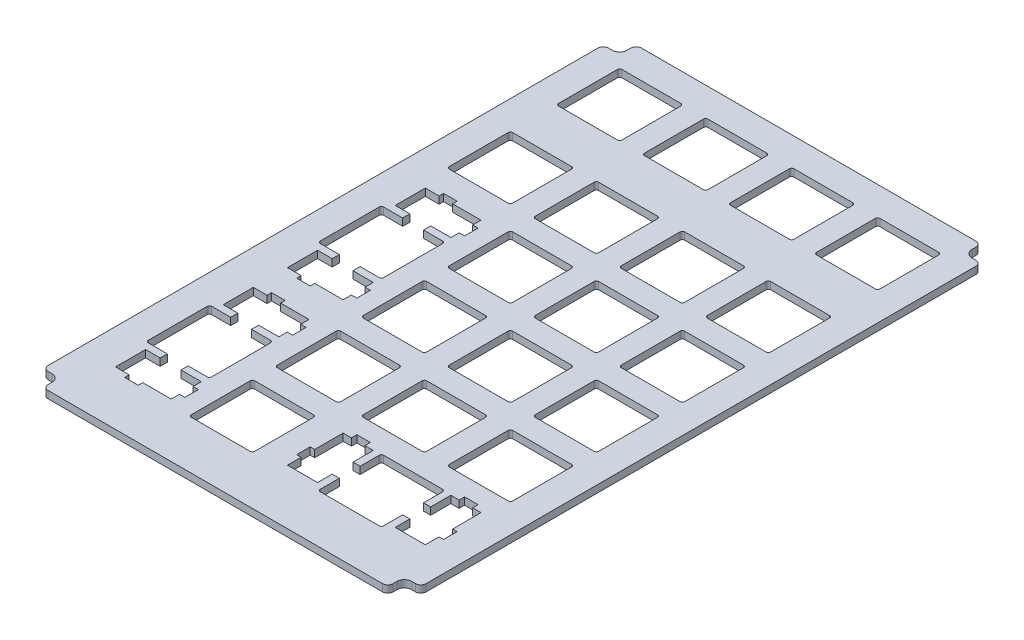
from build123d import *

# Parameters (mm, degrees)
EXTRUDE_1_DEPTH             = 1.6
CUT_EXTRUDE_3_DEPTH         = 1.6
PATTERN_LINEAR_1_COUNT      = 5
PATTERN_LINEAR_1_PITCH      = 19
PATTERN_LINEAR_1_COUNT_DIR2 = 4
PATTERN_LINEAR_1_PITCH_DIR2 = 19
PATTERN_LINEAR_2_COUNT      = 2
PATTERN_LINEAR_2_PITCH      = 100.15
PATTERN_LINEAR_2_COUNT_DIR2 = 4
PATTERN_LINEAR_2_PITCH_DIR2 = 19
CUT_EXTRUDE_2_DEPTH         = 1.6
SKETCH_7_W                  = 35.521117503
SKETCH_7_H                  = 15.86551154
EXTRUDE_2_DEPTH             = 1.6
CUT_EXTRUDE_4_DEPTH         = 1.6


with BuildPart() as part:
    # 草图1 → 凸台-拉伸1 (new body)
    with BuildSketch(Plane(origin=(0, 0, 0), x_dir=(1, 0, 0), z_dir=(0, 1, 0))):
        with BuildLine():
            Line((-11.350806884, 119.165811453), (-10.500806884, 119.165811453))
            ThreePointArc((-10.500806884, 119.165811453), (-9.334080695, 119.649085264), (-8.850806884, 120.815811453))
            Line((-8.850806884, 120.815811453), (-8.850806884, 121.665811453))
            ThreePointArc((-8.850806884, 121.665811453), (-8.513979683, 122.478984252), (-7.700806884, 122.815811453))
            Line((-7.700806884, 122.815811453), (66.199193116, 122.815811453))
            ThreePointArc((66.199193116, 122.815811453), (67.012365914, 122.478984252), (67.349193116, 121.665811453))
            Line((67.349193116, 121.665811453), (67.349193116, 120.815811453))
            ThreePointArc((67.349193116, 120.815811453), (67.832466927, 119.649085264), (68.999193116, 119.165811453))
            Line((68.999193116, 119.165811453), (69.849193116, 119.165811453))
            ThreePointArc((69.849193116, 119.165811453), (70.662365914, 118.828984252), (70.999193116, 118.015811453))
            Line((70.999193116, 118.015811453), (70.999193116, -3.47167721))
            ThreePointArc((70.999193116, -3.47167721), (70.662365914, -4.284850009), (69.849193116, -4.62167721))
            Line((69.849193116, -4.62167721), (68.999193116, -4.62167721))
            ThreePointArc((68.999193116, -4.62167721), (67.832466927, -5.104951021), (67.349193116, -6.27167721))
            Line((67.349193116, -6.27167721), (67.349193116, -7.12167721))
            ThreePointArc((67.349193116, -7.12167721), (67.012365914, -7.934850009), (66.199193116, -8.27167721))
            Line((66.199193116, -8.27167721), (-7.700806884, -8.27167721))
            ThreePointArc((-7.700806884, -8.27167721), (-8.513979683, -7.934850009), (-8.850806884, -7.12167721))
            Line((-8.850806884, -7.12167721), (-8.850806884, -6.27167721))
            ThreePointArc((-8.850806884, -6.27167721), (-9.334080695, -5.104951021), (-10.500806884, -4.62167721))
            Line((-10.500806884, -4.62167721), (-11.350806884, -4.62167721))
            ThreePointArc((-11.350806884, -4.62167721), (-12.163979683, -4.284850009), (-12.500806884, -3.47167721))
            Line((-12.500806884, -3.47167721), (-12.500806884, 118.015811453))
            ThreePointArc((-12.500806884, 118.015811453), (-12.163979683, 118.828984252), (-11.350806884, 119.165811453))
        make_face()
    extrude(amount=EXTRUDE_1_DEPTH)

    # 草图6 → 切除-拉伸3 (cut)
    with BuildSketch(Plane.XZ):
        with BuildLine():
            Line((51.249193116, -2.415811453), (64.249193116, -2.415811453))
            ThreePointArc((64.249193116, -2.415811453), (64.602746506, -2.562258063), (64.749193116, -2.915811453))
            Line((64.749193116, -2.915811453), (64.749193116, -15.915811453))
            ThreePointArc((64.749193116, -15.915811453), (64.602746506, -16.269364844), (64.249193116, -16.415811453))
            Line((64.249193116, -16.415811453), (51.249193116, -16.415811453))
            ThreePointArc((51.249193116, -16.415811453), (50.895639725, -16.269364844), (50.749193116, -15.915811453))
            Line((50.749193116, -15.915811453), (50.749193116, -2.915811453))
            ThreePointArc((50.749193116, -2.915811453), (50.895639725, -2.562258063), (51.249193116, -2.415811453))
        make_face()
    cut_extrude_3 = extrude(amount=-CUT_EXTRUDE_3_DEPTH, mode=Mode.SUBTRACT)

    # 阵列(线性)1: Cut-Extrude 3 5 × 4, 4 skipped
    with Locations(*[(-j * PATTERN_LINEAR_1_PITCH_DIR2, 0, -i * PATTERN_LINEAR_1_PITCH) for i in range(PATTERN_LINEAR_1_COUNT) for j in range(PATTERN_LINEAR_1_COUNT_DIR2) if (i, j) not in ((0, 0), (0, 3), (1, 3), (2, 3), (3, 3))]):
        add(cut_extrude_3, mode=Mode.SUBTRACT)

    # 阵列(线性)2: Cut-Extrude 3 2 × 4, 3 skipped
    with Locations(*[(-j * PATTERN_LINEAR_2_PITCH_DIR2, 0, -i * PATTERN_LINEAR_2_PITCH) for i in range(PATTERN_LINEAR_2_COUNT) for j in range(PATTERN_LINEAR_2_COUNT_DIR2) if (i, j) not in ((0, 0), (0, 1), (0, 2), (0, 3))]):
        add(cut_extrude_3, mode=Mode.SUBTRACT)

    # 草图3 → 切除-拉伸2 (cut)
    with BuildSketch(Plane(origin=(0, 1.6, 0), x_dir=(1, 0, 0), z_dir=(0, 1, 0))):
        with BuildLine():
            Line((-6.250806884, 12.415811453), (-6.250806884, 25.415811453))
            ThreePointArc((-6.250806884, 25.415811453), (-6.104360275, 25.769364844), (-5.750806884, 25.915811453))
            Line((-5.750806884, 25.915811453), (-1.550806884, 25.915811453))
            Line((-1.550806884, 25.915811453), (-1.550806884, 27.495811453))
            Line((-1.550806884, 27.495811453), (-4.780806884, 27.495811453))
            Line((-4.780806884, 27.495811453), (-4.780806884, 34.145811453))
            Line((-4.780806884, 34.145811453), (-1.750806884, 34.145811453))
            Line((-1.750806884, 34.145811453), (-1.750806884, 35.145811453))
            Line((-1.750806884, 35.145811453), (1.249193116, 35.145811453))
            Line((1.249193116, 35.145811453), (1.249193116, 34.145811453))
            Line((1.249193116, 34.145811453), (7.519193116, 34.145811453))
            Line((7.519193116, 34.145811453), (7.519193116, 32.320811453))
            Line((7.519193116, 32.320811453), (8.719193116, 32.320811453))
            Line((8.719193116, 32.320811453), (8.719193116, 29.320811453))
            Line((8.719193116, 29.320811453), (7.519193116, 29.320811453))
            Line((7.519193116, 29.320811453), (7.519193116, 27.495811453))
            Line((7.519193116, 27.495811453), (3.049193116, 27.495811453))
            Line((3.049193116, 27.495811453), (3.049193116, 25.915811453))
            Line((3.049193116, 25.915811453), (7.249193116, 25.915811453))
            ThreePointArc((7.249193116, 25.915811453), (7.602746506, 25.769364844), (7.749193116, 25.415811453))
            Line((7.749193116, 25.415811453), (7.749193116, 12.415811453))
            ThreePointArc((7.749193116, 12.415811453), (7.602746506, 12.062258063), (7.249193116, 11.915811453))
            Line((7.249193116, 11.915811453), (3.049193116, 11.915811453))
            Line((3.049193116, 11.915811453), (3.049193116, 10.335811453))
            Line((3.049193116, 10.335811453), (7.519193116, 10.335811453))
            Line((7.519193116, 10.335811453), (7.519193116, 8.510811453))
            Line((7.519193116, 8.510811453), (8.719193116, 8.510811453))
            Line((8.719193116, 8.510811453), (8.719193116, 5.510811453))
            Line((8.719193116, 5.510811453), (7.519193116, 5.510811453))
            Line((7.519193116, 5.510811453), (7.519193116, 3.685811453))
            Line((7.519193116, 3.685811453), (1.249193116, 3.685811453))
            Line((1.249193116, 3.685811453), (1.249193116, 2.685811453))
            Line((1.249193116, 2.685811453), (-1.750806884, 2.685811453))
            Line((-1.750806884, 2.685811453), (-1.750806884, 3.685811453))
            Line((-1.750806884, 3.685811453), (-4.780806884, 3.685811453))
            Line((-4.780806884, 3.685811453), (-4.780806884, 10.335811453))
            Line((-4.780806884, 10.335811453), (-1.550806884, 10.335811453))
            Line((-1.550806884, 10.335811453), (-1.550806884, 11.915811453))
            Line((-1.550806884, 11.915811453), (-5.750806884, 11.915811453))
            ThreePointArc((-5.750806884, 11.915811453), (-6.104360275, 12.062258063), (-6.250806884, 12.415811453))
        make_face()
        with BuildLine():
            Line((-6.250806884, 50.415811453), (-6.250806884, 63.415811453))
            ThreePointArc((-6.250806884, 63.415811453), (-6.104360275, 63.769364844), (-5.750806884, 63.915811453))
            Line((-5.750806884, 63.915811453), (-1.550806884, 63.915811453))
            Line((-1.550806884, 63.915811453), (-1.550806884, 65.495811453))
            Line((-1.550806884, 65.495811453), (-4.780806884, 65.495811453))
            Line((-4.780806884, 65.495811453), (-4.780806884, 72.145811453))
            Line((-4.780806884, 72.145811453), (-1.750806884, 72.145811453))
            Line((-1.750806884, 72.145811453), (-1.750806884, 73.145811453))
            Line((-1.750806884, 73.145811453), (1.249193116, 73.145811453))
            Line((1.249193116, 73.145811453), (1.249193116, 72.145811453))
            Line((1.249193116, 72.145811453), (7.519193116, 72.145811453))
            Line((7.519193116, 72.145811453), (7.519193116, 70.320811453))
            Line((7.519193116, 70.320811453), (8.719193116, 70.320811453))
            Line((8.719193116, 70.320811453), (8.719193116, 67.320811453))
            Line((8.719193116, 67.320811453), (7.519193116, 67.320811453))
            Line((7.519193116, 67.320811453), (7.519193116, 65.495811453))
            Line((7.519193116, 65.495811453), (3.049193116, 65.495811453))
            Line((3.049193116, 65.495811453), (3.049193116, 63.915811453))
            Line((3.049193116, 63.915811453), (7.249193116, 63.915811453))
            ThreePointArc((7.249193116, 63.915811453), (7.602746506, 63.769364844), (7.749193116, 63.415811453))
            Line((7.749193116, 63.415811453), (7.749193116, 50.415811453))
            ThreePointArc((7.749193116, 50.415811453), (7.602746506, 50.062258063), (7.249193116, 49.915811453))
            Line((7.249193116, 49.915811453), (3.049193116, 49.915811453))
            Line((3.049193116, 49.915811453), (3.049193116, 48.335811453))
            Line((3.049193116, 48.335811453), (7.519193116, 48.335811453))
            Line((7.519193116, 48.335811453), (7.519193116, 46.510811453))
            Line((7.519193116, 46.510811453), (8.719193116, 46.510811453))
            Line((8.719193116, 46.510811453), (8.719193116, 43.510811453))
            Line((8.719193116, 43.510811453), (7.519193116, 43.510811453))
            Line((7.519193116, 43.510811453), (7.519193116, 41.685811453))
            Line((7.519193116, 41.685811453), (1.249193116, 41.685811453))
            Line((1.249193116, 41.685811453), (1.249193116, 40.685811453))
            Line((1.249193116, 40.685811453), (-1.750806884, 40.685811453))
            Line((-1.750806884, 40.685811453), (-1.750806884, 41.685811453))
            Line((-1.750806884, 41.685811453), (-4.780806884, 41.685811453))
            Line((-4.780806884, 41.685811453), (-4.780806884, 48.335811453))
            Line((-4.780806884, 48.335811453), (-1.550806884, 48.335811453))
            Line((-1.550806884, 48.335811453), (-1.550806884, 49.915811453))
            Line((-1.550806884, 49.915811453), (-5.750806884, 49.915811453))
            ThreePointArc((-5.750806884, 49.915811453), (-6.104360275, 50.062258063), (-6.250806884, 50.415811453))
        make_face()
    extrude(amount=-CUT_EXTRUDE_2_DEPTH, mode=Mode.SUBTRACT)

    # 草图7 → 凸台-拉伸2 (add)
    with BuildSketch(Plane(origin=(0, 1.6, 0), x_dir=(1, 0, 0), z_dir=(0, 1, 0))):
        with Locations((48.619669698, 9.052037262)):
            Rectangle(SKETCH_7_W, SKETCH_7_H)
    extrude(amount=-EXTRUDE_2_DEPTH)

    # 草图8 → 切除-拉伸4 (cut)
    with BuildSketch(Plane(origin=(0, 1.6, 0), x_dir=(1, 0, 0), z_dir=(0, 1, 0))):
        with BuildLine():
            Line((58.654193116, 16.185811453), (56.829193116, 16.185811453))
            Line((56.829193116, 16.185811453), (56.829193116, 11.715811453))
            Line((56.829193116, 11.715811453), (55.249193116, 11.715811453))
            Line((55.249193116, 11.715811453), (55.249193116, 15.915811453))
            ThreePointArc((55.249193116, 15.915811453), (55.102746506, 16.269364844), (54.749193116, 16.415811453))
            Line((54.749193116, 16.415811453), (41.749193116, 16.415811453))
            ThreePointArc((41.749193116, 16.415811453), (41.395639725, 16.269364844), (41.249193116, 15.915811453))
            Line((41.249193116, 15.915811453), (41.249193116, 11.715811453))
            Line((41.249193116, 11.715811453), (39.669193116, 11.715811453))
            Line((39.669193116, 11.715811453), (39.669193116, 16.185811453))
            Line((39.669193116, 16.185811453), (37.844193116, 16.185811453))
            Line((37.844193116, 16.185811453), (37.844193116, 17.385811453))
            Line((37.844193116, 17.385811453), (34.844193116, 17.385811453))
            Line((34.844193116, 17.385811453), (34.844193116, 16.185811453))
            Line((34.844193116, 16.185811453), (33.019193116, 16.185811453))
            Line((33.019193116, 16.185811453), (33.019193116, 9.915811453))
            Line((33.019193116, 9.915811453), (32.019193116, 9.915811453))
            Line((32.019193116, 9.915811453), (32.019193116, 6.915811453))
            Line((32.019193116, 6.915811453), (33.019193116, 6.915811453))
            Line((33.019193116, 6.915811453), (33.019193116, 3.885811453))
            Line((33.019193116, 3.885811453), (39.669193116, 3.885811453))
            Line((39.669193116, 3.885811453), (39.669193116, 7.115811453))
            Line((39.669193116, 7.115811453), (41.249193116, 7.115811453))
            Line((41.249193116, 7.115811453), (41.249193116, 2.915811453))
            ThreePointArc((41.249193116, 2.915811453), (41.395639725, 2.562258063), (41.749193116, 2.415811453))
            Line((41.749193116, 2.415811453), (54.749193116, 2.415811453))
            ThreePointArc((54.749193116, 2.415811453), (55.102746506, 2.562258063), (55.249193116, 2.915811453))
            Line((55.249193116, 2.915811453), (55.249193116, 7.115811453))
            Line((55.249193116, 7.115811453), (56.829193116, 7.115811453))
            Line((56.829193116, 7.115811453), (56.829193116, 3.885811453))
            Line((56.829193116, 3.885811453), (63.479193116, 3.885811453))
            Line((63.479193116, 3.885811453), (63.479193116, 6.915811453))
            Line((63.479193116, 6.915811453), (64.479193116, 6.915811453))
            Line((64.479193116, 6.915811453), (64.479193116, 9.915811453))
            Line((64.479193116, 9.915811453), (63.479193116, 9.915811453))
            Line((63.479193116, 9.915811453), (63.479193116, 16.185811453))
            Line((63.479193116, 16.185811453), (61.654193116, 16.185811453))
            Line((61.654193116, 16.185811453), (61.654193116, 17.385811453))
            Line((61.654193116, 17.385811453), (58.654193116, 17.385811453))
            Line((58.654193116, 17.385811453), (58.654193116, 16.185811453))
        make_face()
    extrude(amount=-CUT_EXTRUDE_4_DEPTH, mode=Mode.SUBTRACT)


solid = part.part
